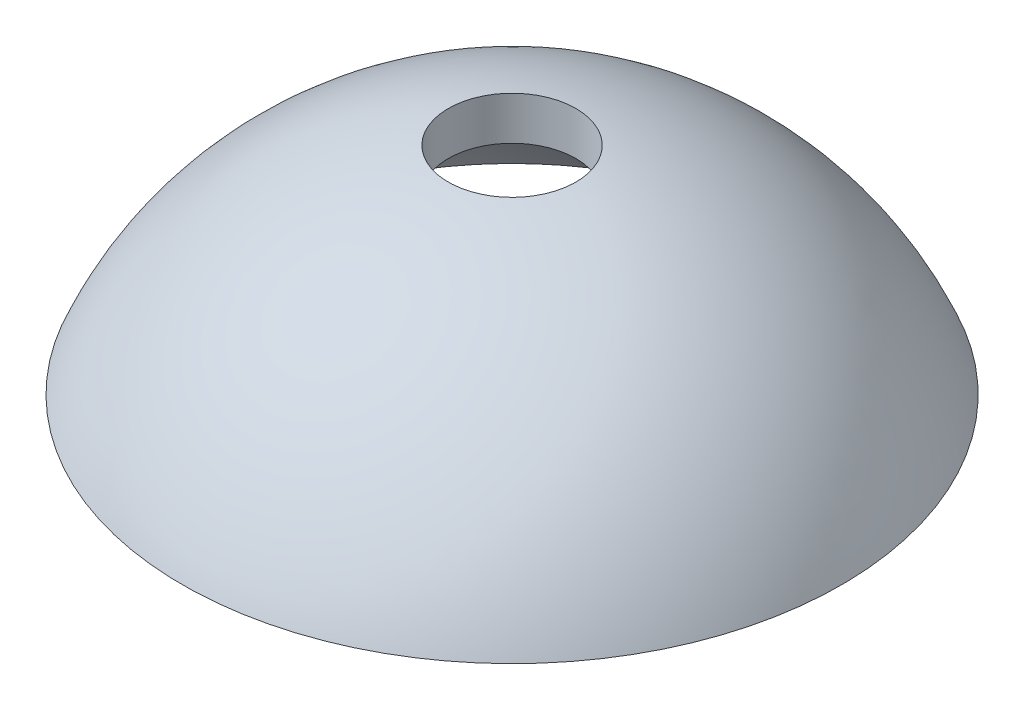
from build123d import *


with BuildPart() as part:
    # Sketch1 → Revolve1 (revolve)
    with BuildSketch(Plane(origin=(0, 0, 0), x_dir=(0, 0, -1), z_dir=(1, 0, 0))):
        with BuildLine():
            ThreePointArc((9.747024336, 11.050855655), (11.77415263, 8.859753042), (13.318105864, 6.305073378))
            Line((13.318105864, 6.305073378), (15.5, 6.310044658))
            ThreePointArc((15.5, 6.310044658), (10.551716519, 12.989532019), (3, 16.464102271))
            Line((3, 16.464102271), (3, 14.426569035))
            ThreePointArc((3, 14.426569035), (6.593217543, 13.177836566), (9.747024336, 11.050855655))
        make_face()
    revolve(axis=Axis((0, 0, 0), (0, 1, 0)))


solid = part.part
